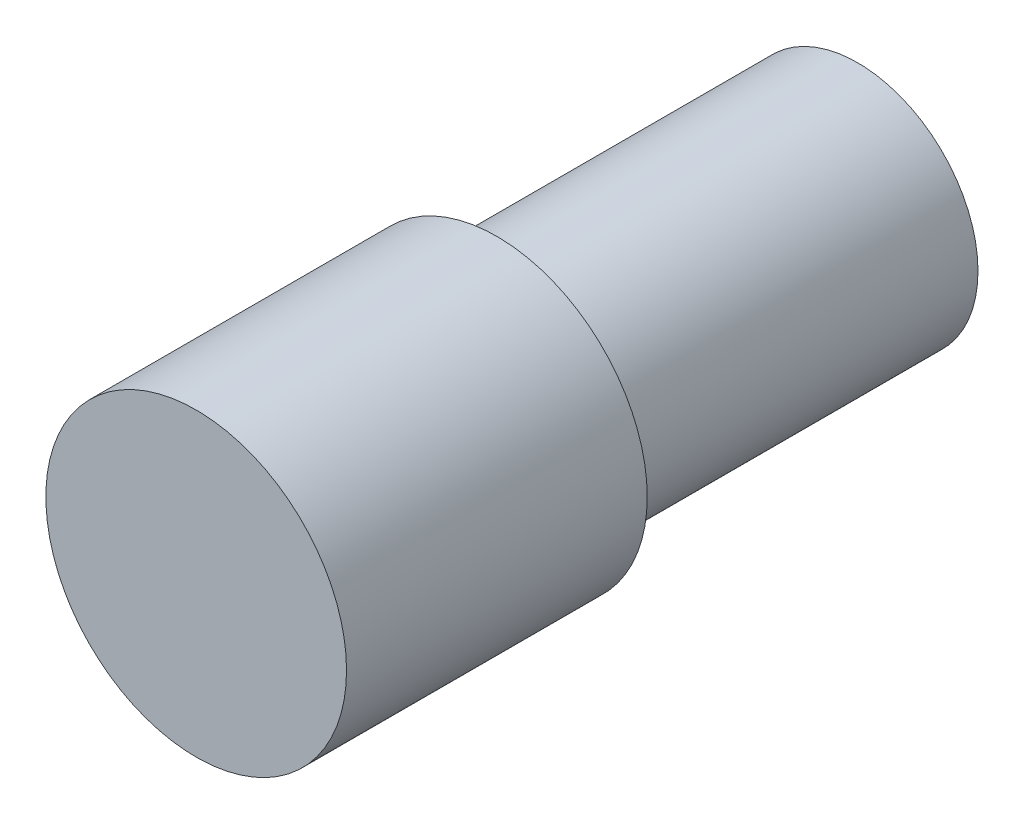
from build123d import *

# Parameters (mm, degrees)
ESQUISSE1_R        = 5
BOSS_EXTRU_1_DEPTH = 10
ESQUISSE2_R        = 4
BOSS_EXTRU_2_DEPTH = 12


with BuildPart() as part:
    # Esquisse1 → Boss.-Extru.1 (new body)
    with BuildSketch(Plane.XY):
        Circle(ESQUISSE1_R)
    extrude(amount=BOSS_EXTRU_1_DEPTH)

    # Esquisse2 → Boss.-Extru.2 (add)
    with BuildSketch(Plane(origin=(0, 0, 0), x_dir=(-1, 0, 0), z_dir=(0, 0, -1))):
        Circle(ESQUISSE2_R)
    extrude(amount=BOSS_EXTRU_2_DEPTH)


solid = part.part
